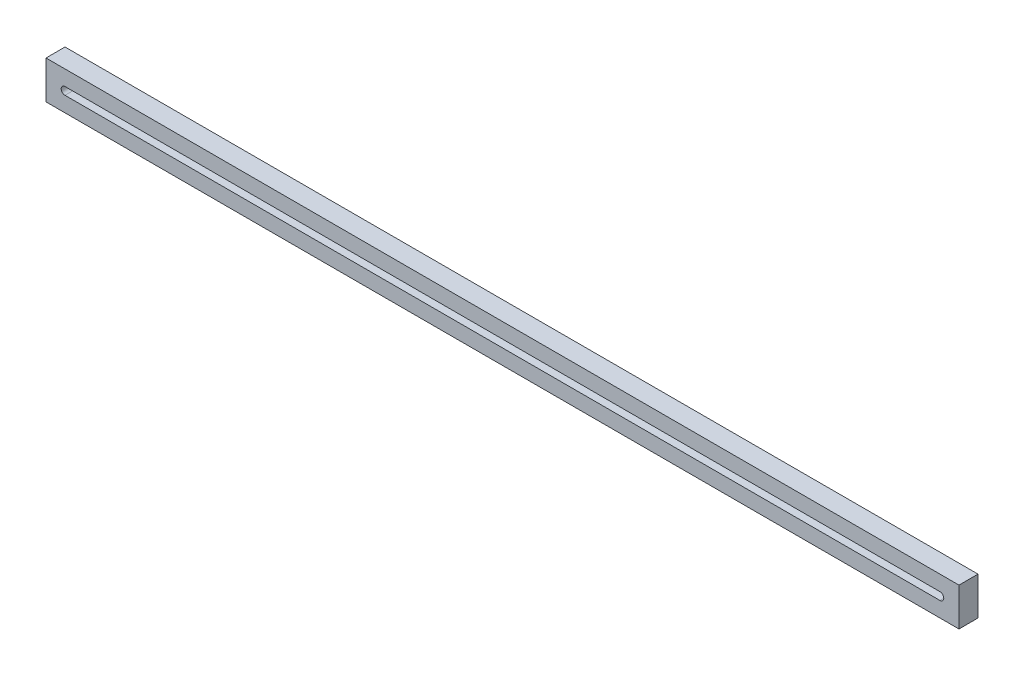
from build123d import *

# Parameters (mm, degrees)
SKETCH1_W           = 304.8
SKETCH1_H           = 12.7
BOSS_EXTRUDE1_DEPTH = 6.35


with BuildPart() as part:
    # Sketch1 → Boss-Extrude1 (new body)
    with BuildSketch(Plane.XY):
        Rectangle(SKETCH1_W, SKETCH1_H)
        with BuildLine():
            ThreePointArc((-146.05, -1.27), (-147.32, 0), (-146.05, 1.27))
            Line((-146.05, 1.27), (146.05, 1.27))
            ThreePointArc((146.05, 1.27), (146.948025612, 0.898025612), (147.32, 0))
            ThreePointArc((147.32, 0), (146.948025612, -0.898025612), (146.05, -1.27))
            Line((146.05, -1.27), (-146.05, -1.27))
        make_face(mode=Mode.SUBTRACT)
    extrude(amount=BOSS_EXTRUDE1_DEPTH)


solid = part.part
